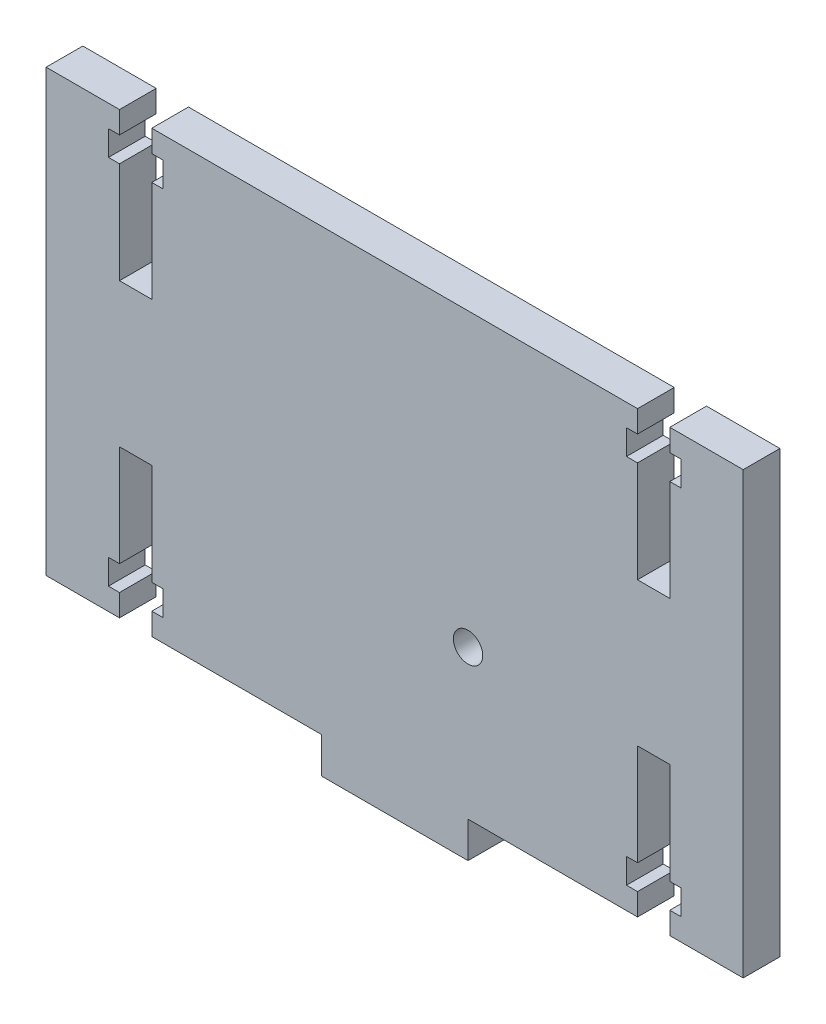
from build123d import *

# Parameters (mm, degrees)
BOSS_EXTRUDE1_DEPTH = 5
CUT_EXTRUDE1_DEPTH  = 5
SKETCH4_R           = 2
CUT_EXTRUDE2_DEPTH  = 5


with BuildPart() as part:
    # Sketch1 → Boss-Extrude1 (new body)
    with BuildSketch(Plane.XY):
        Polygon((10, -30), (47.5, -30), (47.5, 30), (-47.5, 30), (-47.5, -30), (-10, -30), (-10, -34.9), (10, -34.9), align=None)
    extrude(amount=BOSS_EXTRUDE1_DEPTH)

    # Sketch3 → Cut-Extrude1 (cut)
    with BuildSketch(Plane.XY.offset(5)):
        Polygon((-33.1, -27), (-33.1, -30), (-37.5, -30), (-37.5, -27), (-39, -27), (-39, -23.6), (-37.5, -23.6), (-37.5, -9.8), (-33.1, -9.8), (-33.1, -23.6), (-31.6, -23.6), (-31.6, -27), align=None)
        Polygon((37.5, -30), (37.5, -27), (39, -27), (39, -23.6), (37.5, -23.6), (37.5, -9.8), (33.1, -9.8), (33.1, -23.6), (31.6, -23.6), (31.6, -27), (33.1, -27), (33.1, -30), align=None)
        Polygon((33.1, 27), (33.1, 30), (37.5, 30), (37.5, 27), (39, 27), (39, 23.6), (37.5, 23.6), (37.5, 9.8), (33.1, 9.8), (33.1, 23.6), (31.6, 23.6), (31.6, 27), align=None)
        Polygon((-37.5, 30), (-37.5, 27), (-39, 27), (-39, 23.6), (-37.5, 23.6), (-37.5, 9.8), (-33.1, 9.8), (-33.1, 23.6), (-31.6, 23.6), (-31.6, 27), (-33.1, 27), (-33.1, 30), align=None)
    extrude(amount=-CUT_EXTRUDE1_DEPTH, mode=Mode.SUBTRACT)

    # Sketch4 → Cut-Extrude2 (cut)
    with BuildSketch(Plane.XY.offset(5)):
        with Locations((10, -9.7)):
            Circle(SKETCH4_R)
    extrude(amount=-CUT_EXTRUDE2_DEPTH, mode=Mode.SUBTRACT)


solid = part.part
